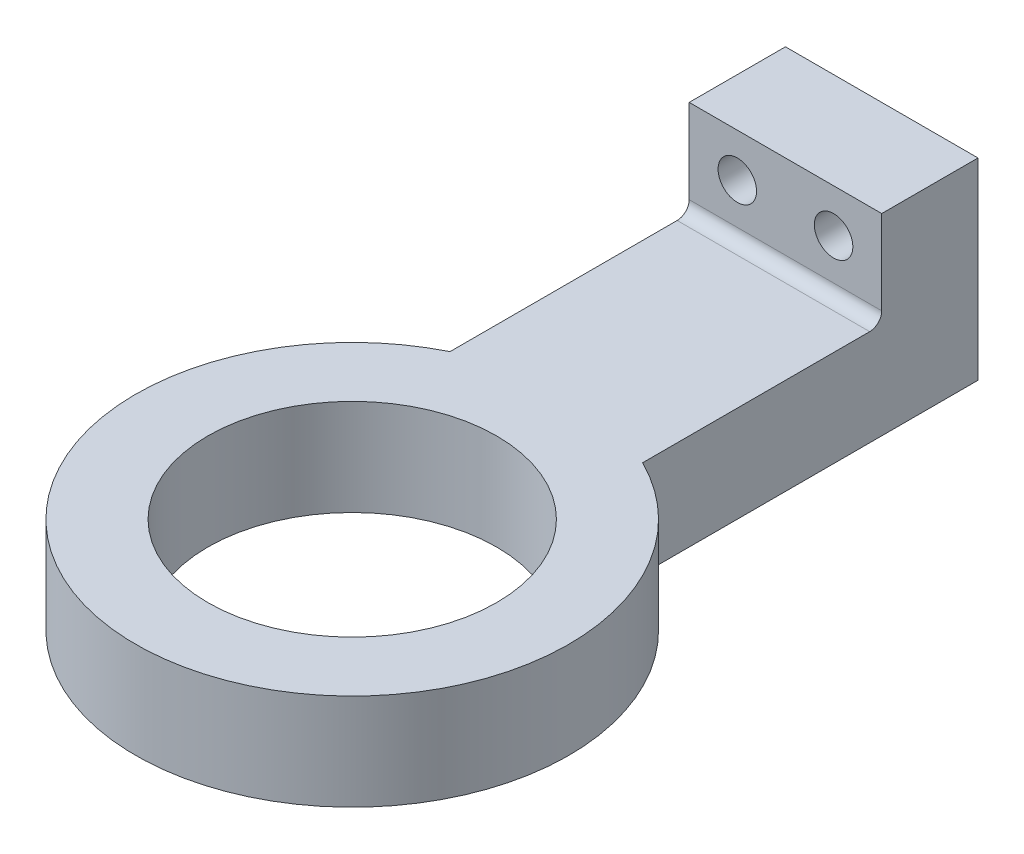
from build123d import *

# Parameters (mm, degrees)
SKETCH1_R           = 45
SKETCH1_R_2         = 30
BOSS_EXTRUDE1_DEPTH = 20
SKETCH2_W           = 40
SKETCH2_H           = 80
BOSS_EXTRUDE2_DEPTH = 20
SKETCH3_W           = 40
SKETCH3_H           = 20
BOSS_EXTRUDE3_DEPTH = 20
FILLET1_R           = 2.5
SKETCH4_R           = 4
CUT_EXTRUDE1_DEPTH  = 21


with BuildPart() as part:
    # Sketch1 → Boss-Extrude1 (new body)
    with BuildSketch(Plane(origin=(0, 0, 0), x_dir=(1, 0, 0), z_dir=(0, 1, 0))):
        Circle(SKETCH1_R)
        Circle(SKETCH1_R_2, mode=Mode.SUBTRACT)
    extrude(amount=BOSS_EXTRUDE1_DEPTH)

    # Sketch2 → Boss-Extrude2 (add)
    with BuildSketch(Plane(origin=(0, 0, 0), x_dir=(1, 0, 0), z_dir=(0, 1, 0))):
        with Locations((0, 70)):
            Rectangle(SKETCH2_W, SKETCH2_H)
    extrude(amount=BOSS_EXTRUDE2_DEPTH)

    # Sketch3 → Boss-Extrude3 (add)
    with BuildSketch(Plane(origin=(0, 20, 0), x_dir=(1, 0, 0), z_dir=(0, 1, 0))):
        with Locations((0, 100)):
            Rectangle(SKETCH3_W, SKETCH3_H)
    extrude(amount=BOSS_EXTRUDE3_DEPTH)

    # Fillet1
    fillet1_edges = [part.edges().sort_by_distance(p)[0] for p in [
        (0, 20, -90),
    ]]
    fillet(fillet1_edges, radius=FILLET1_R)

    # Sketch4 → Cut-Extrude1 (cut, through all)
    with BuildSketch(Plane.XY.offset(-90)):
        with Locations((10, 31)):
            Circle(SKETCH4_R)
        with Locations((-10, 31)):
            Circle(SKETCH4_R)
    extrude(amount=-CUT_EXTRUDE1_DEPTH, mode=Mode.SUBTRACT)


solid = part.part
